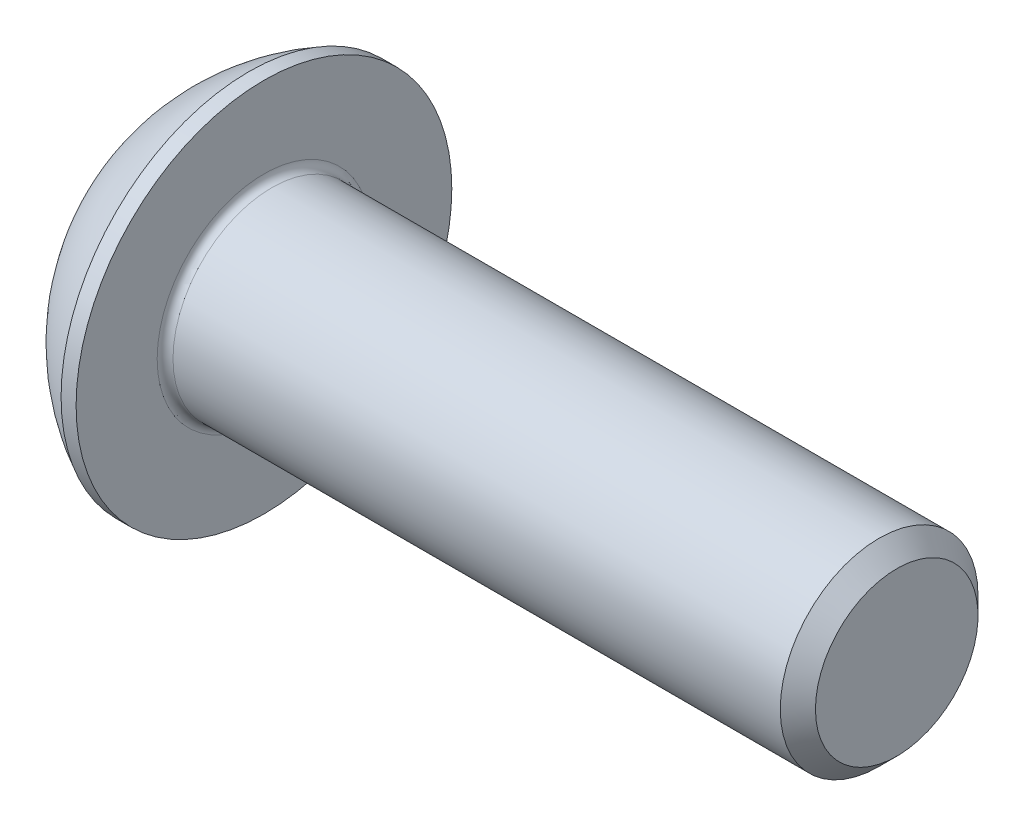
from build123d import *

# Parameters (mm, degrees)
FILLET1_R   = 0.2
HEX_2_DEPTH = 1.56


with BuildPart() as part:
    # BodySke → BaseBody (revolve)
    with BuildSketch(Plane.XY):
        with BuildLine():
            Line((18.75, 0), (18.75, 2.055))
            Line((18.75, 2.055), (18.305, 2.5))
            Line((18.305, 2.5), (2.75, 2.5))
            Line((2.75, 2.5), (2.75, 4.75))
            Line((2.75, 4.75), (2.37, 4.75))
            ThreePointArc((2.37, 4.75), (0.992680215, 3.754414901), (0, 2.375))
            Line((0, 2.375), (0, 0))
            Line((0, 0), (18.75, 0))
        make_face()
    revolve(axis=Axis((0, 0, 0), (1, 0, 0)))

    # Fillet1
    fillet1_edges = [part.edges().sort_by_distance(p)[0] for p in [
        (2.75, -2.5, 0),
    ]]
    fillet(fillet1_edges, radius=FILLET1_R)

    # Sketch2 → PreBroach (revolve, cut)
    with BuildSketch(Plane.XY):
        Polygon((0, 1.5), (1.56, 1.5), (2.426025404, 0), (0, 0), align=None)
    revolve(axis=Axis((0, 0, 0), (1, 0, 0)), mode=Mode.SUBTRACT)

    # Sketch3 → Hex 2 (cut)
    with BuildSketch(Plane(origin=(0, 0, 0), x_dir=(0, 0, -1), z_dir=(1, 0, 0))):
        Polygon((-1.5, -0.866025404), (-1.5, 0.866025404), (0, 1.732050808), (1.5, 0.866025404), (1.5, -0.866025404), (0, -1.732050808), align=None)
    extrude(amount=HEX_2_DEPTH, mode=Mode.SUBTRACT)


solid = part.part
